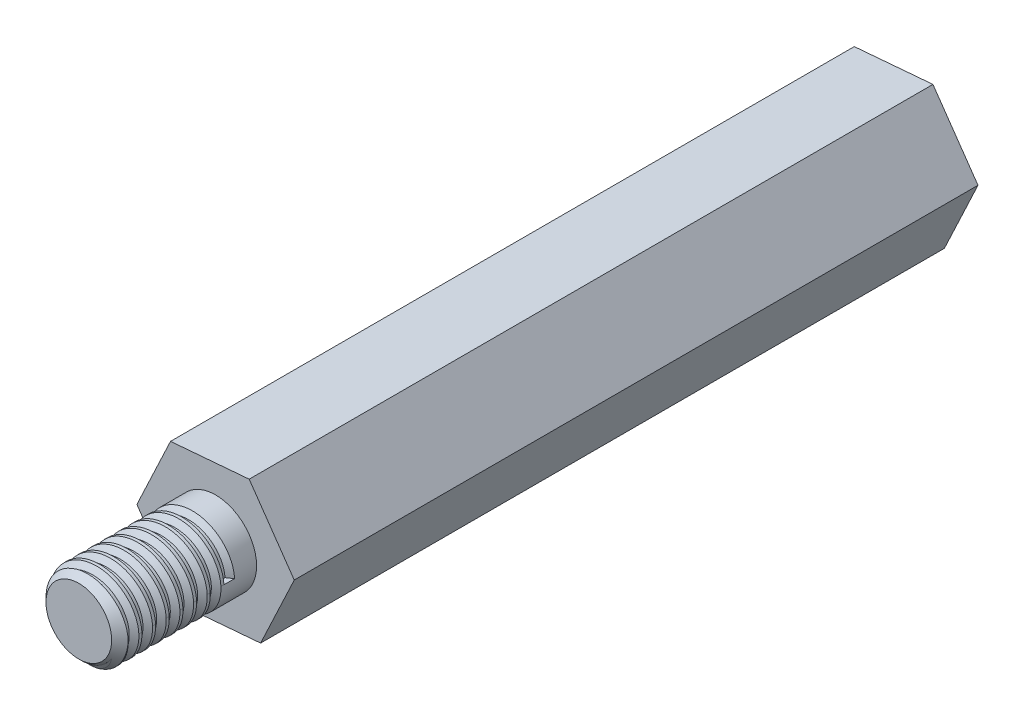
from build123d import *

# Parameters (mm, degrees)
EXTRUDE_1_DEPTH        = 25
HOLE_WIZARD_M3_1_D     = 2.5
HOLE_WIZARD_M3_1_DEPTH = 15
HOLE_WIZARD_M3_1_TIP   = 0.751075774
SKETCH_3_R             = 1.5
EXTRUDE_2_DEPTH        = 5
CHAMFER_1_SIZE         = 0.3
SWEEP_2_PITCH          = 0.5
SWEEP_2_HEIGHT         = 4
SWEEP_2_RADIUS         = 1.5
SWEEP_2_START_ANGLE    = -180


with BuildPart() as part:
    # Sketch 1 → Extrude 1 (new body)
    with BuildSketch(Plane.XY):
        Polygon((1.647343323, -2.37056814), (2.876643893, 0.241357097), (1.229300569, 2.611925237), (-1.647343323, 2.37056814), (-2.876643893, -0.241357097), (-1.229300569, -2.611925237), align=None)
    extrude(amount=EXTRUDE_1_DEPTH)

    # Hole Wizard M3 _1
    with Locations(Plane(origin=(0, 0, 0), x_dir=(-1, 0, 0), z_dir=(0, 0, -1))):
        with Locations((0, 0)):
            Hole(HOLE_WIZARD_M3_1_D / 2, depth=HOLE_WIZARD_M3_1_DEPTH)
            with Locations((0, 0, -(HOLE_WIZARD_M3_1_DEPTH + HOLE_WIZARD_M3_1_TIP / 2))):  # 118° drill point
                Cone(0, HOLE_WIZARD_M3_1_D / 2, HOLE_WIZARD_M3_1_TIP, mode=Mode.SUBTRACT)

    # Sketch 3 → Extrude 2 (add)
    with BuildSketch(Plane.XY.offset(25)):
        Circle(SKETCH_3_R)
    extrude(amount=EXTRUDE_2_DEPTH)

    # Chamfer 1
    chamfer_1_edges = [part.edges().sort_by_distance(p)[0] for p in [
        (-1.5, 0, 30),
    ]]
    chamfer(chamfer_1_edges, length=CHAMFER_1_SIZE)

    # Sweep 2: sweep along a helix
    with BuildLine() as sweep_2_path:
        add(Helix(SWEEP_2_PITCH, SWEEP_2_HEIGHT, SWEEP_2_RADIUS, center=(0, 0, 30), direction=(0, 0, -1), mode=Mode.PRIVATE).rotate(Axis((0, 0, 30), (0, 0, -1)), SWEEP_2_START_ANGLE))
    # Sketch 5 → Sweep 2 (sweep, cut)
    with BuildSketch(Plane(origin=(0, 0, 0), x_dir=(1, 0, 0), z_dir=(0, 1, 0))):
        Polygon((1.543237988, -30.225), (1.543237988, -29.775), (1.293237988, -29.95), (1.293237988, -30.05), align=None)
    sweep(path=sweep_2_path.line, is_frenet=True, mode=Mode.SUBTRACT)


solid = part.part
